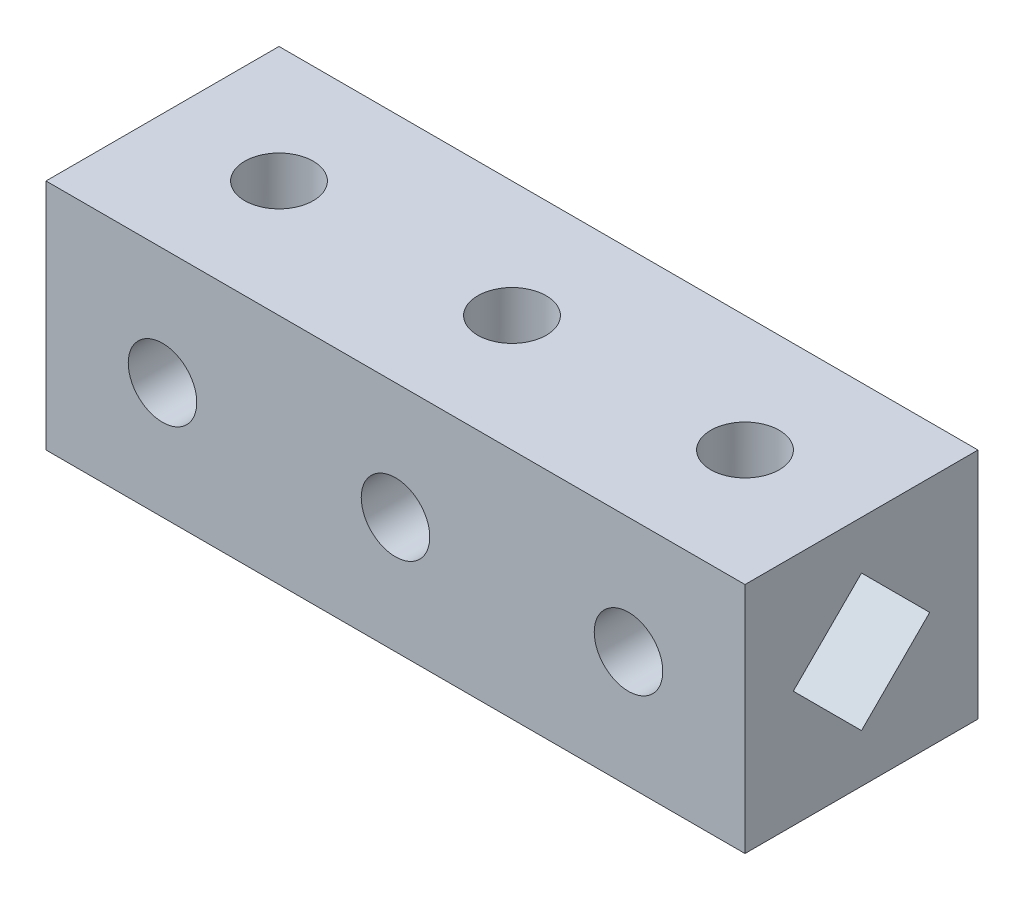
from build123d import *

# Parameters (mm, degrees)
SKETCH1_W           = 51
SKETCH1_H           = 17
SKETCH1_R           = 2.5
BOSS_EXTRUDE1_DEPTH = 17
SKETCH6_OUTSIDE_W   = 64.276
SKETCH6_OUTSIDE_H   = 30.276
SKETCH6_OUTSIDE_W_2 = 51
SKETCH6_OUTSIDE_H_2 = 17
SKETCH6_OUTSIDE_R   = 2.5
CUT_EXTRUDE10_DEPTH = 18
SKETCH7_OUTSIDE_W   = 30.276
SKETCH7_OUTSIDE_H   = 30.276
SKETCH7_OUTSIDE_W_2 = 17
SKETCH7_OUTSIDE_H_2 = 17
CUT_EXTRUDE11_DEPTH = 17
SKETCH9_OUTSIDE_W   = 30.276
SKETCH9_OUTSIDE_H   = 30.276
SKETCH9_OUTSIDE_W_2 = 17
SKETCH9_OUTSIDE_H_2 = 17
CUT_EXTRUDE12_DEPTH = 17


with BuildPart() as part:
    # sketch1 → Boss-Extrude1 (new body)
    with BuildSketch(Plane(origin=(0, 0, 0), x_dir=(1, 0, 0), z_dir=(0, 1, 0))):
        with Locations((25.5, -8.5)):
            Rectangle(SKETCH1_W, SKETCH1_H)
        with Locations((8.5, -8.5)):
            Circle(SKETCH1_R, mode=Mode.SUBTRACT)
        with Locations((25.5, -8.5)):
            Circle(SKETCH1_R, mode=Mode.SUBTRACT)
        with Locations((42.5, -8.5)):
            Circle(SKETCH1_R, mode=Mode.SUBTRACT)
    extrude(amount=BOSS_EXTRUDE1_DEPTH)

    # Sketch6 outside → Cut-Extrude10 (cut, through all)
    with BuildSketch(Plane(origin=(0, 0, 0), x_dir=(-1, 0, 0), z_dir=(0, 0, -1))):
        with Locations((-25.5, 8.5)):
            Rectangle(SKETCH6_OUTSIDE_W, SKETCH6_OUTSIDE_H)
        with Locations((-25.5, 8.5)):
            Rectangle(SKETCH6_OUTSIDE_W_2, SKETCH6_OUTSIDE_H_2, mode=Mode.SUBTRACT)
        with Locations((-42.5, 8.5)):
            Circle(SKETCH6_OUTSIDE_R)
        with Locations((-25.5, 8.5)):
            Circle(SKETCH6_OUTSIDE_R)
        with Locations((-8.5, 8.5)):
            Circle(SKETCH6_OUTSIDE_R)
    extrude(amount=-CUT_EXTRUDE10_DEPTH, mode=Mode.SUBTRACT)

    # Sketch7 outside → Cut-Extrude11 (cut)
    with BuildSketch(Plane(origin=(51, 0, 0), x_dir=(0, 0, -1), z_dir=(1, 0, 0))):
        with Locations((-8.5, 8.5)):
            Rectangle(SKETCH7_OUTSIDE_W, SKETCH7_OUTSIDE_H)
        with Locations((-8.5, 8.5)):
            Rectangle(SKETCH7_OUTSIDE_W_2, SKETCH7_OUTSIDE_H_2, mode=Mode.SUBTRACT)
        Polygon((-8.5, 13.47803174), (-3.52196826, 8.5), (-8.5, 3.52196826), (-13.47803174, 8.5), align=None)
    extrude(amount=-CUT_EXTRUDE11_DEPTH, mode=Mode.SUBTRACT)

    # Sketch9 outside → Cut-Extrude12 (cut)
    with BuildSketch(Plane.ZY):
        with Locations((8.5, 8.5)):
            Rectangle(SKETCH9_OUTSIDE_W, SKETCH9_OUTSIDE_H)
        with Locations((8.5, 8.5)):
            Rectangle(SKETCH9_OUTSIDE_W_2, SKETCH9_OUTSIDE_H_2, mode=Mode.SUBTRACT)
        Polygon((8.5, 13.47803174), (3.52196826, 8.5), (8.5, 3.52196826), (13.47803174, 8.5), align=None)
    extrude(amount=-CUT_EXTRUDE12_DEPTH, mode=Mode.SUBTRACT)


solid = part.part
